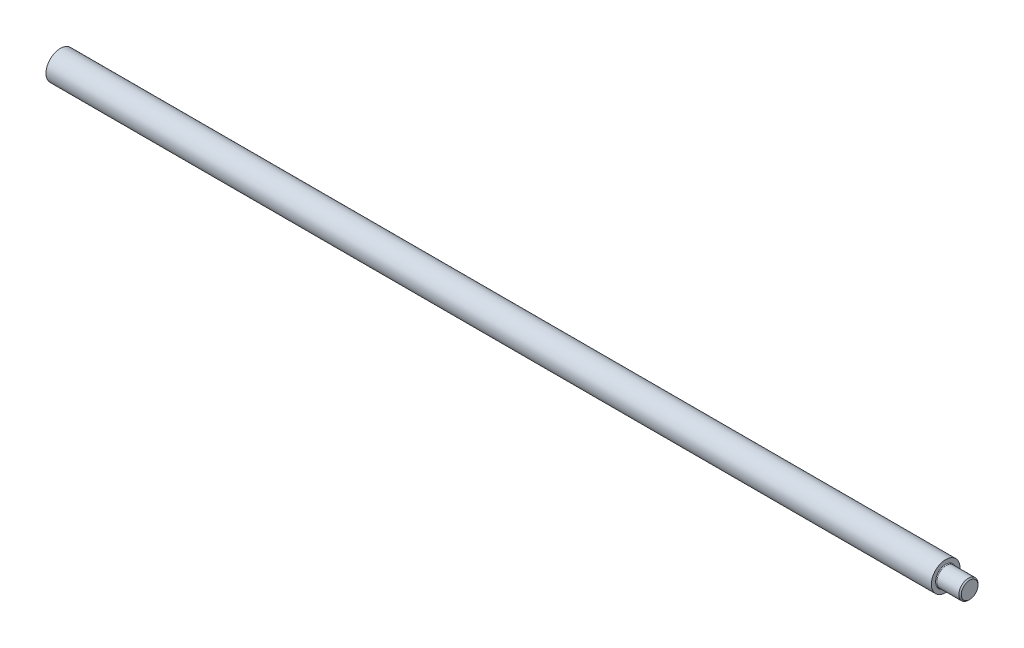
from build123d import *


with BuildPart() as part:
    # Sketch1 → Revolve1 (revolve)
    with BuildSketch(Plane.XY):
        with BuildLine():
            Line((0, 6), (0, 0))
            Line((0, 0), (380, 0))
            Line((380, 0), (380, 3.5))
            Line((380, 3.5), (379.5, 4))
            Line((379.5, 4), (370.3, 4))
            ThreePointArc((370.3, 4), (370.087867966, 4.087867966), (370, 4.3))
            Line((370, 4.3), (370, 6))
            Line((370, 6), (0, 6))
        make_face()
    revolve(axis=Axis((0, 0, 0), (1, 0, 0)))


solid = part.part
